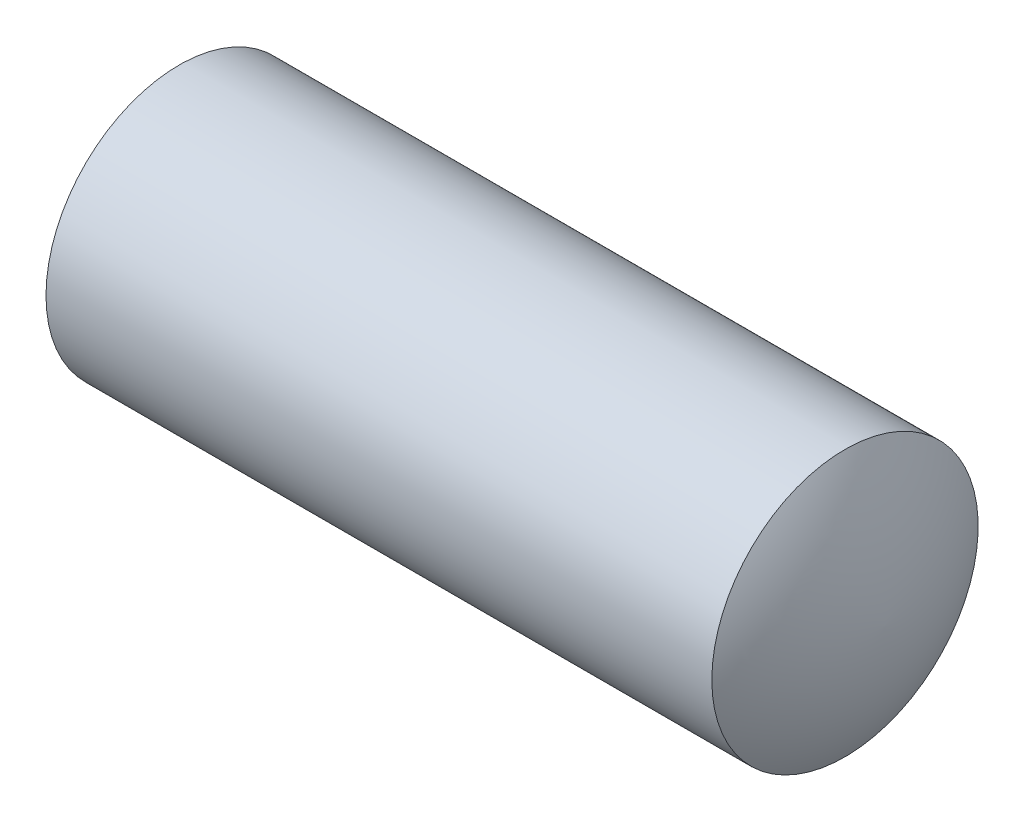
from build123d import *


with BuildPart() as part:
    # Эскиз1 → Повернуть2 (revolve)
    with BuildSketch(Plane.XY):
        with BuildLine():
            Line((0, 2), (10, 2))
            ThreePointArc((10, 2), (10.432805569, 1.039841671), (10.6, 0))
            Line((10.6, 0), (-0.6, 0))
            ThreePointArc((-0.6, 0), (-0.432805569, 1.039841671), (0, 2))
        make_face()
    revolve(axis=Axis((0, 0, 0), (1, 0, 0)))


solid = part.part
